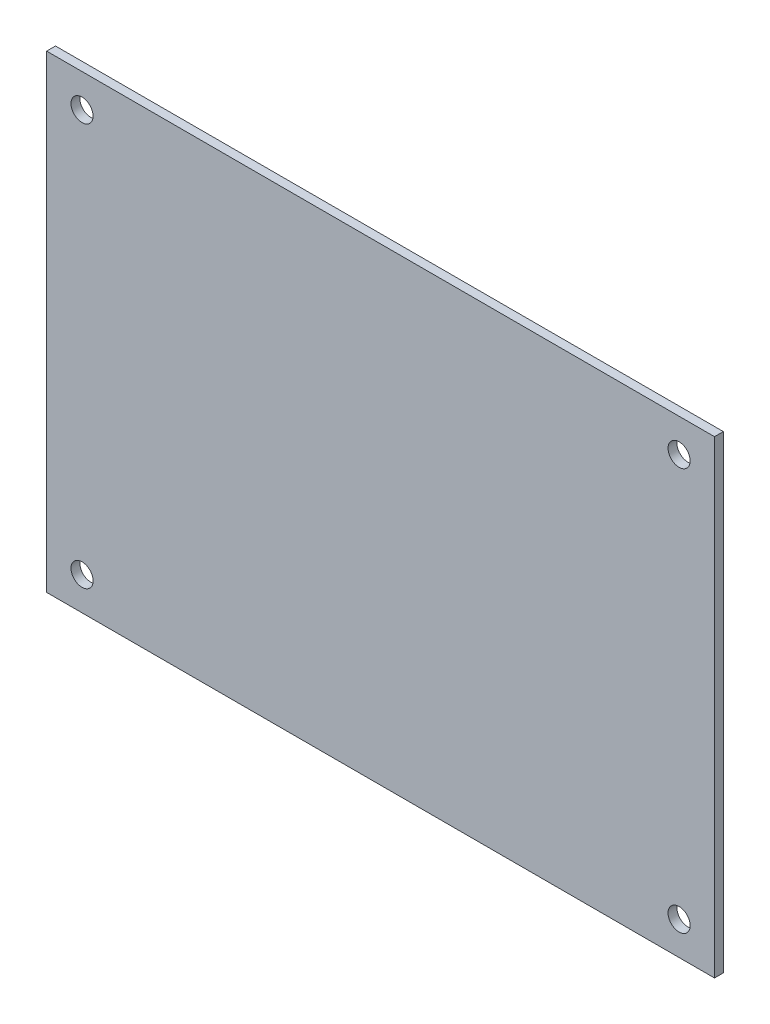
from build123d import *

# Parameters (mm, degrees)
SKETCH1_W           = 155
SKETCH1_H           = 110
BOSS_EXTRUDE1_DEPTH = 80
SKETCH2_W           = 151
SKETCH2_H           = 106
CUT_EXTRUDE1_DEPTH  = 78
SKETCH3_R           = 2.5
CUT_EXTRUDE2_DEPTH  = 2
SKETCH7_R           = 1.6
CUT_EXTRUDE7_DEPTH  = 2
SKETCH4_W           = 27.5
SKETCH4_H           = 46.8
CUT_EXTRUDE8_DEPTH  = 2
SKETCH8_W           = 4
SKETCH8_H           = 53
CUT_EXTRUDE9_DEPTH  = 2
SKETCH9_W           = 14
SKETCH9_H           = 14
CUT_EXTRUDE10_DEPTH = 2
SKETCH10_W          = 25.2
SKETCH10_H          = 71.2
SKETCH10_R          = 1.25
CUT_EXTRUDE12_DEPTH = 2
SKETCH11_R          = 2.5
SKETCH11_R_2        = 4.5
CUT_EXTRUDE13_DEPTH = 2
SKETCH12_W          = 151
SKETCH12_H          = 2
CUT_EXTRUDE14_DEPTH = 80


with BuildPart() as part:
    # Sketch1 → Boss-Extrude1 (new body)
    with BuildSketch(Plane.XY):
        with Locations((77.5, 55)):
            Rectangle(SKETCH1_W, SKETCH1_H)
    extrude(amount=BOSS_EXTRUDE1_DEPTH)

    # Sketch2 → Cut-Extrude1 (cut)
    with BuildSketch(Plane.XY.offset(80)):
        with Locations((77.5, 55)):
            Rectangle(SKETCH2_W, SKETCH2_H)
    extrude(amount=-CUT_EXTRUDE1_DEPTH, mode=Mode.SUBTRACT)

    # Sketch3 → Cut-Extrude2 (cut)
    with BuildSketch(Plane.XY.offset(2)):
        with Locations((145, 100.5)):
            Circle(SKETCH3_R)
        with Locations((145, 9.5)):
            Circle(SKETCH3_R)
        with Locations((10, 9.5)):
            Circle(SKETCH3_R)
        with Locations((10, 100.5)):
            Circle(SKETCH3_R)
    extrude(amount=-CUT_EXTRUDE2_DEPTH, mode=Mode.SUBTRACT)

    # Sketch7 → Cut-Extrude7 (cut)
    with BuildSketch(Plane(origin=(0, 110, 0), x_dir=(1, 0, 0), z_dir=(0, 1, 0))):
        with Locations((44.48, -20.14450396)):
            Circle(SKETCH7_R)
        with Locations((95.28, -17.14)):
            Circle(SKETCH7_R)
        with Locations((95.28, -62.86)):
            Circle(SKETCH7_R)
        with Locations((44.48, -47.62)):
            Circle(SKETCH7_R)
    extrude(amount=-CUT_EXTRUDE7_DEPTH, mode=Mode.SUBTRACT)

    # Sketch4 → Cut-Extrude8 (cut)
    with BuildSketch(Plane(origin=(155, 0, 0), x_dir=(0, 0, -1), z_dir=(1, 0, 0))):
        with Locations((-40, 82.5)):
            Rectangle(SKETCH4_W, SKETCH4_H)
    extrude(amount=-CUT_EXTRUDE8_DEPTH, mode=Mode.SUBTRACT)

    # Sketch8 → Cut-Extrude9 (cut)
    with BuildSketch(Plane(origin=(155, 0, 0), x_dir=(0, 0, -1), z_dir=(1, 0, 0))):
        with Locations((-68, 28.5)):
            Rectangle(SKETCH8_W, SKETCH8_H)
        with Locations((-76, 28.5)):
            Rectangle(SKETCH8_W, SKETCH8_H)
        with Locations((-60, 28.5)):
            Rectangle(SKETCH8_W, SKETCH8_H)
        with Locations((-52, 28.5)):
            Rectangle(SKETCH8_W, SKETCH8_H)
        with Locations((-44, 28.5)):
            Rectangle(SKETCH8_W, SKETCH8_H)
        with Locations((-36, 28.5)):
            Rectangle(SKETCH8_W, SKETCH8_H)
        with Locations((-28, 28.5)):
            Rectangle(SKETCH8_W, SKETCH8_H)
        with Locations((-20, 28.5)):
            Rectangle(SKETCH8_W, SKETCH8_H)
        with Locations((-12, 28.5)):
            Rectangle(SKETCH8_W, SKETCH8_H)
        with Locations((-4, 28.5)):
            Rectangle(SKETCH8_W, SKETCH8_H)
    extrude(amount=-CUT_EXTRUDE9_DEPTH, mode=Mode.SUBTRACT)

    # Sketch9 → Cut-Extrude10 (cut)
    with BuildSketch(Plane(origin=(0, 110, 0), x_dir=(1, 0, 0), z_dir=(0, 1, 0))):
        with Locations((120, -19)):
            Rectangle(SKETCH9_W, SKETCH9_H)
    extrude(amount=-CUT_EXTRUDE10_DEPTH, mode=Mode.SUBTRACT)

    # Sketch10 → Cut-Extrude12 (cut)
    with BuildSketch(Plane.ZY):
        with Locations((58, 55)):
            Rectangle(SKETCH10_W, SKETCH10_H)
        with Locations((42.5, 92.5)):
            Circle(SKETCH10_R)
        with Locations((73.5, 92.5)):
            Circle(SKETCH10_R)
        with Locations((42.5, 17.5)):
            Circle(SKETCH10_R)
        with Locations((73.5, 17.5)):
            Circle(SKETCH10_R)
    extrude(amount=-CUT_EXTRUDE12_DEPTH, mode=Mode.SUBTRACT)

    # Sketch11 → Cut-Extrude13 (cut)
    with BuildSketch(Plane.ZY):
        with Locations((20, 55)):
            Circle(SKETCH11_R)
        with Locations((20, 40)):
            Circle(SKETCH11_R)
        with Locations((20, 25)):
            Circle(SKETCH11_R)
        with Locations((20, 82.5)):
            Circle(SKETCH11_R_2)
    extrude(amount=-CUT_EXTRUDE13_DEPTH, mode=Mode.SUBTRACT)

    # Sketch12 → Cut-Extrude14 (cut)
    with BuildSketch(Plane.XY.offset(80)):
        Polygon((0, 110), (0, 108), (2, 108), (153, 108), (155, 108), (155, 110), align=None)
        Polygon((2, 108), (0, 108), (0, 0), (2, 0), (2, 2), align=None)
        Polygon((155, 108), (153, 108), (153, 2), (153, 0), (155, 0), align=None)
        with Locations((77.5, 1)):
            Rectangle(SKETCH12_W, SKETCH12_H)
    extrude(amount=-CUT_EXTRUDE14_DEPTH, mode=Mode.SUBTRACT)


solid = part.part
